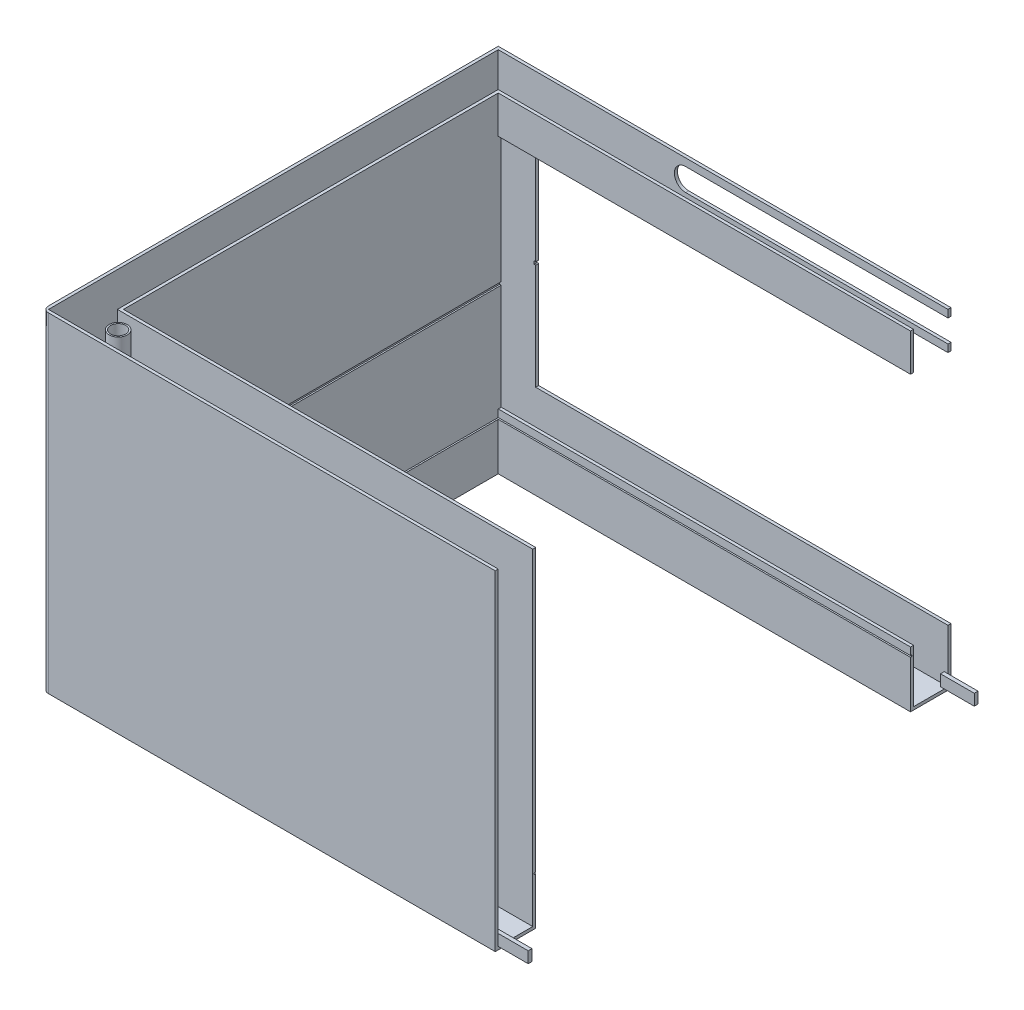
from build123d import *

# Parameters (mm, degrees)
BOSS_EXTRUDE1_DEPTH      = 440
BOSS_EXTRUDE2_DEPTH      = 440
BOSS_EXTRUDE3_DEPTH      = 4
SKETCH4_W                = 500
SKETCH4_H                = 4
CUT_EXTRUDE1_DEPTH       = 2
CUT_EXTRUDE3_DEPTH       = 1
CUT_EXTRUDE3_DEPTH_BACK  = 1
SKETCH12_W               = 5
SKETCH12_H               = 15
BOSS_EXTRUDE4_DEPTH      = 40
BOSS_EXTRUDE4_DEPTH_BACK = 5
SKETCH11_W               = 5
SKETCH11_H               = 15
BOSS_EXTRUDE5_DEPTH      = 40
BOSS_EXTRUDE5_DEPTH_BACK = 5
CUT_EXTRUDE5_START       = -54
CUT_EXTRUDE5_DEPTH       = 54
CUT_EXTRUDE6_DEPTH       = 4
FILLET1_R                = 8
CUT_EXTRUDE7_DEPTH       = 2
SKETCH17_R               = 10
CUT_EXTRUDE8_DEPTH       = 10
SKETCH18_R               = 12
SKETCH18_R_2             = 10
BOSS_EXTRUDE6_DEPTH      = 436
SKETCH19_R               = 10
CUT_EXTRUDE9_DEPTH       = 25
SKETCH20_R               = 12
SKETCH20_R_2             = 10
BOSS_EXTRUDE7_DEPTH      = 23


with BuildPart() as part:
    # Sketch1 → Boss-Extrude1 (new body)
    with BuildSketch(Plane(origin=(0, 0, 0), x_dir=(1, 0, 0), z_dir=(0, 1, 0))):
        Polygon((0, 300), (-600, 300), (-600, -300), (0, -300), (0, -304), (-604, -304), (-604, 304), (0, 304), align=None)
    extrude(amount=BOSS_EXTRUDE1_DEPTH)



with BuildPart() as body_2:
    # Sketch2 → Boss-Extrude2 (new body)
    with BuildSketch(Plane(origin=(0, 0, 0), x_dir=(1, 0, 0), z_dir=(0, 1, 0))):
        Polygon((0, 250), (-550, 250), (-550, -250), (0, -250), (0, -254), (-554, -254), (-554, 254), (0, 254), align=None)
    extrude(amount=BOSS_EXTRUDE2_DEPTH)


with BuildPart() as part_1:
    add(part.part)

    add(body_2.part)  # Boss-Extrude3 merges body 2
    # Sketch3 → Boss-Extrude3 (add)
    with BuildSketch(Plane(origin=(0, 0, 0), x_dir=(1, 0, 0), z_dir=(0, 1, 0))):
        Polygon((0, -254), (0, -300), (-600, -300), (-600, 300), (0, 300), (0, 254), (-554, 254), (-554, -254), align=None)
    extrude(amount=BOSS_EXTRUDE3_DEPTH)

    # Sketch4 → Cut-Extrude1 (cut)
    with BuildSketch(Plane(origin=(-550, 0, 0), x_dir=(0, 0, -1), z_dir=(1, 0, 0))):
        with Locations((0, 218)):
            Rectangle(SKETCH4_W, SKETCH4_H)
    extrude(amount=-CUT_EXTRUDE1_DEPTH, mode=Mode.SUBTRACT)

    # Sketch7 → Cut-Extrude3 (cut, two sides)
    with BuildSketch(Plane(origin=(0, 64, 0), x_dir=(1, 0, 0), z_dir=(0, 1, 0))) as cut_extrude3_sk:
        Polygon((-550, 250), (0, 250), (0, 252), (-552, 252), (-552, -252), (0, -252), (0, -250), (-550, -250), align=None)
    extrude(amount=CUT_EXTRUDE3_DEPTH, mode=Mode.SUBTRACT)
    extrude(cut_extrude3_sk.sketch, amount=-CUT_EXTRUDE3_DEPTH_BACK, mode=Mode.SUBTRACT)

    # Sketch13 → Cut-Extrude5 (cut)
    with BuildSketch(Plane(origin=(0, 0, -304), x_dir=(-1, 0, 0), z_dir=(0, 0, -1)).offset(CUT_EXTRUDE5_START)):
        Polygon((0, 390), (550, 390), (550, 220), (552, 220), (552, 216), (550, 216), (550, 75), (0, 75), align=None)
    extrude(amount=CUT_EXTRUDE5_DEPTH, mode=Mode.SUBTRACT)

    # Sketch14 → Cut-Extrude6 (cut)
    with BuildSketch(Plane(origin=(0, 0, -304), x_dir=(-1, 0, 0), z_dir=(0, 0, -1))):
        with BuildLine():
            Line((0, 400), (0, 430))
            Line((0, 430), (350, 430))
            ThreePointArc((350, 430), (365, 415), (350, 400))
            Line((350, 400), (0, 400))
        make_face()
    extrude(amount=-CUT_EXTRUDE6_DEPTH, mode=Mode.SUBTRACT)

    # Fillet1
    fillet1_edges = [part_1.edges().sort_by_distance(p)[0] for p in [
        (-604, 220, 304),
    ]]
    fillet(fillet1_edges, radius=FILLET1_R)

    # Sketch15 → Cut-Extrude7 (cut)
    with BuildSketch(Plane.XZ):
        Polygon((-600, -300), (-588, -300), (-588, -298), (-598, -298), (-598, -288), (-600, -288), align=None)
    cut_extrude7 = extrude(amount=-CUT_EXTRUDE7_DEPTH, mode=Mode.SUBTRACT)

    # Mirror1: Cut-Extrude7 across plane
    add(cut_extrude7.mirror(Plane.XY), mode=Mode.SUBTRACT)

    # Sketch17 → Cut-Extrude8 (cut)
    with BuildSketch(Plane(origin=(0, 4, 0), x_dir=(1, 0, 0), z_dir=(0, 1, 0))):
        with Locations((-530, -277)):
            Circle(SKETCH17_R)
    extrude(amount=-CUT_EXTRUDE8_DEPTH, mode=Mode.SUBTRACT)

    # Sketch18 → Boss-Extrude6 (add)
    with BuildSketch(Plane(origin=(0, 4, 0), x_dir=(1, 0, 0), z_dir=(0, 1, 0))):
        with Locations((-530, -277)):
            Circle(SKETCH18_R)
        with Locations((-530, -277)):
            Circle(SKETCH18_R_2, mode=Mode.SUBTRACT)
    extrude(amount=BOSS_EXTRUDE6_DEPTH)

    # Sketch19 → Cut-Extrude9 (cut)
    with BuildSketch(Plane(origin=(0, 0, 250), x_dir=(-1, 0, 0), z_dir=(0, 0, -1))):
        with Locations((530, 85)):
            Circle(SKETCH19_R)
    extrude(amount=-CUT_EXTRUDE9_DEPTH, mode=Mode.SUBTRACT)

    # Sketch20 → Boss-Extrude7 (add)
    with BuildSketch(Plane.XY.offset(254)):
        with Locations((-530, 85)):
            Circle(SKETCH20_R)
        with Locations((-530, 85)):
            Circle(SKETCH20_R_2, mode=Mode.SUBTRACT)
    extrude(amount=BOSS_EXTRUDE7_DEPTH)


with BuildPart() as body_2_2:
    # Sketch12 → Boss-Extrude4 (new body, two sides)
    with BuildSketch(Plane(origin=(0, 0, 0), x_dir=(0, 0, -1), z_dir=(1, 0, 0))) as boss_extrude4_sk:
        with Locations((297.5, 11.5)):
            Rectangle(SKETCH12_W, SKETCH12_H)
    extrude(amount=BOSS_EXTRUDE4_DEPTH)
    extrude(boss_extrude4_sk.sketch, amount=-BOSS_EXTRUDE4_DEPTH_BACK)


with BuildPart() as body_3:
    # Sketch11 → Boss-Extrude5 (new body, two sides)
    with BuildSketch(Plane(origin=(0, 0, 0), x_dir=(0, 0, -1), z_dir=(1, 0, 0))) as boss_extrude5_sk:
        with Locations((-297.5, 11.5)):
            Rectangle(SKETCH11_W, SKETCH11_H)
    extrude(amount=BOSS_EXTRUDE5_DEPTH)
    extrude(boss_extrude5_sk.sketch, amount=-BOSS_EXTRUDE5_DEPTH_BACK)


solid = Compound([part_1.part, body_2_2.part, body_3.part])
